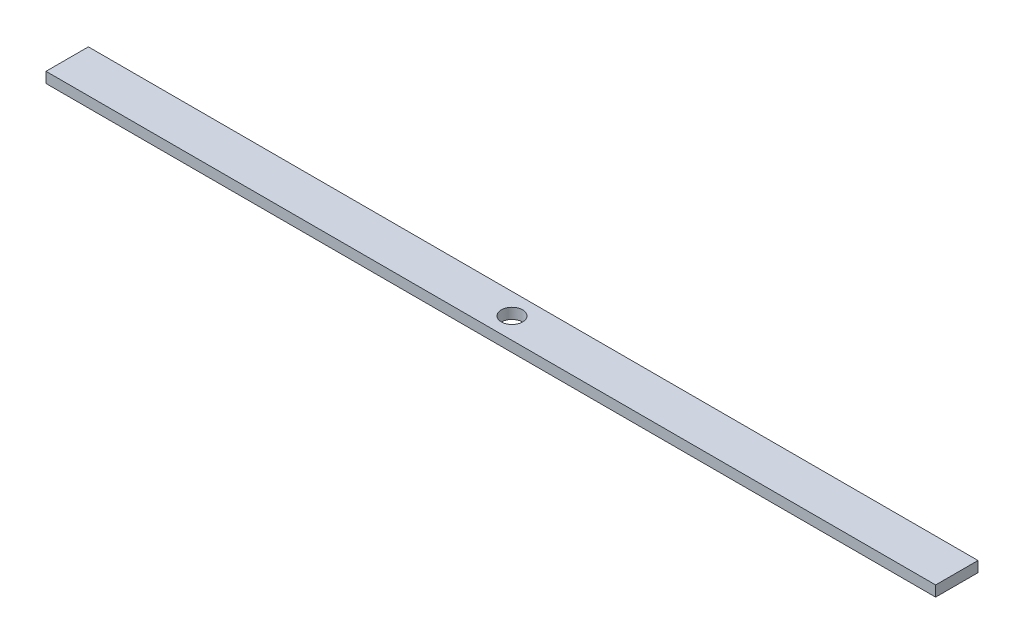
from build123d import *

# Parameters (mm, degrees)
SKETCH1_W           = 533.4
SKETCH1_H           = 25.4
SKETCH1_R           = 6.35
BOSS_EXTRUDE1_DEPTH = 6.35


with BuildPart() as part:
    # Sketch1 → Boss-Extrude1 (new body)
    with BuildSketch(Plane(origin=(0, 0, 0), x_dir=(1, 0, 0), z_dir=(0, 1, 0))):
        Rectangle(SKETCH1_W, SKETCH1_H)
        Circle(SKETCH1_R, mode=Mode.SUBTRACT)
    extrude(amount=BOSS_EXTRUDE1_DEPTH)


solid = part.part
